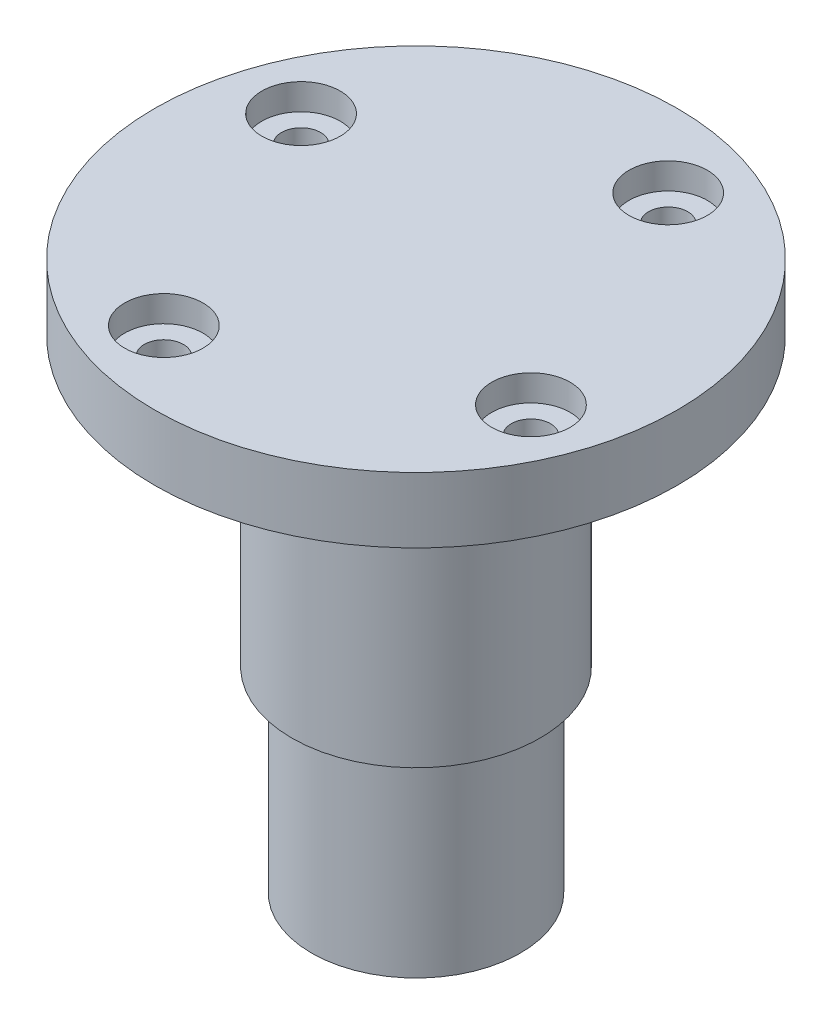
from build123d import *

# Parameters (mm, degrees)
SKETCH_1_R          = 8
EXTRUDE_1_DEPTH     = 37
SKETCH_2_R          = 9.5
EXTRUDE_2_DEPTH     = 22
SKETCH_3_R          = 20
EXTRUDE_3_DEPTH     = 5
SKETCH_4_R          = 1.5
CUT_EXTRUDE_1_DEPTH = 5
SKETCH_5_R          = 3
CUT_EXTRUDE_2_DEPTH = 2


with BuildPart() as part:
    # 草图1 → 凸台-拉伸1 (new body)
    with BuildSketch(Plane(origin=(0, 0, 0), x_dir=(1, 0, 0), z_dir=(0, 1, 0))):
        Circle(SKETCH_1_R)
    extrude(amount=EXTRUDE_1_DEPTH)

    # 草图2 → 凸台-拉伸2 (add)
    with BuildSketch(Plane(origin=(0, 37, 0), x_dir=(1, 0, 0), z_dir=(0, 1, 0))):
        Circle(SKETCH_2_R)
    extrude(amount=-EXTRUDE_2_DEPTH)

    # 草图3 → 凸台-拉伸3 (add)
    with BuildSketch(Plane(origin=(0, 37, 0), x_dir=(1, 0, 0), z_dir=(0, 1, 0))):
        Circle(SKETCH_3_R)
    extrude(amount=EXTRUDE_3_DEPTH)

    # 草图4 → 切除-拉伸1 (cut)
    with BuildSketch(Plane(origin=(0, 42, 0), x_dir=(1, 0, 0), z_dir=(0, 1, 0))):
        with Locations((-14.050368693, 5.252346102)):
            Circle(SKETCH_4_R)
        with Locations((5.252346102, 14.050368693)):
            Circle(SKETCH_4_R)
        with Locations((14.050368693, -5.252346102)):
            Circle(SKETCH_4_R)
        with Locations((-5.252346102, -14.050368693)):
            Circle(SKETCH_4_R)
    extrude(amount=-CUT_EXTRUDE_1_DEPTH, mode=Mode.SUBTRACT)

    # 草图5 → 切除-拉伸2 (cut)
    with BuildSketch(Plane(origin=(0, 42, 0), x_dir=(1, 0, 0), z_dir=(0, 1, 0))):
        with Locations((-14.050368693, 5.252346102)):
            Circle(SKETCH_5_R)
        with Locations((5.252346102, 14.050368693)):
            Circle(SKETCH_5_R)
        with Locations((14.050368693, -5.252346102)):
            Circle(SKETCH_5_R)
        with Locations((-5.252346102, -14.050368693)):
            Circle(SKETCH_5_R)
    extrude(amount=-CUT_EXTRUDE_2_DEPTH, mode=Mode.SUBTRACT)


solid = part.part
